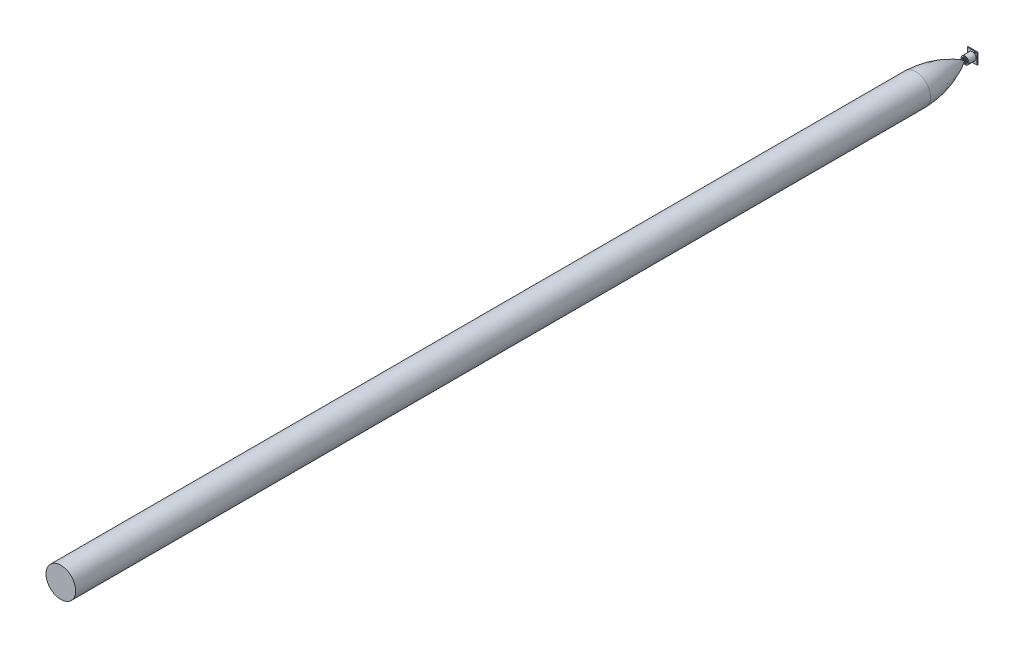
from build123d import *

# Parameters (mm, degrees)
SKETCH1_W          = 19.9
SKETCH1_H          = 22.1
EXTRUDE1_DEPTH     = 1.5875
SKETCH2_R          = 7.747
EXTRUDE2_DEPTH     = 14.7955
SKETCH3_R          = 0.635
EXTRUDE3_DEPTH     = 2.0955
SKETCH5_R          = 1.55
CUT_EXTRUDE1_DEPTH = 2.5875
SKETCH6_R          = 0.5
CUT_EXTRUDE2_DEPTH = 2.5875


with BuildPart() as part:
    # Sketch1 → Extrude1 (new body)
    with BuildSketch(Plane.XY):
        Rectangle(SKETCH1_W, SKETCH1_H)
    extrude(amount=EXTRUDE1_DEPTH)

    # Sketch5 → Cut-Extrude1 (cut, through all)
    with BuildSketch(Plane.XY.offset(1.5875)):
        with Locations((5.19, 8.49)):
            Circle(SKETCH5_R)
        with Locations((-7.41, -8.51)):
            Circle(SKETCH5_R)
    extrude(amount=-CUT_EXTRUDE1_DEPTH, mode=Mode.SUBTRACT)

    # Sketch6 → Cut-Extrude2 (cut, through all)
    with BuildSketch(Plane.XY.offset(1.5875)):
        with Locations((8.75, 5.89)):
            Circle(SKETCH6_R)
        with Locations((8.75, 3.35)):
            Circle(SKETCH6_R)
        with Locations((8.75, 0.81)):
            Circle(SKETCH6_R)
        with Locations((8.75, -1.73)):
            Circle(SKETCH6_R)
        with Locations((8.75, -4.27)):
            Circle(SKETCH6_R)
        with Locations((8.75, -6.81)):
            Circle(SKETCH6_R)
        with Locations((8.75, -9.35)):
            Circle(SKETCH6_R)
    extrude(amount=-CUT_EXTRUDE2_DEPTH, mode=Mode.SUBTRACT)


with BuildPart() as body_2:
    # Sketch2 → Extrude2 (new body)
    with BuildSketch(Plane.XY.offset(1.5875)):
        Circle(SKETCH2_R)
    extrude(amount=EXTRUDE2_DEPTH)

    # Sketch3 → Extrude3 (cut)
    with BuildSketch(Plane.XY.offset(16.383)):
        with BuildLine():
            Line((3.570260811, 2.647878914), (4.675743477, 3.286129629))
            ThreePointArc((4.675743477, 3.286129629), (0, 5.715), (-4.675743477, 3.286129629))
            Line((-4.675743477, 3.286129629), (-3.570260811, 2.647878914))
            ThreePointArc((-3.570260811, 2.647878914), (0, 4.445), (3.570260811, 2.647878914))
        make_face()
        with BuildLine():
            Line((-4.078260811, 1.767997104), (-5.183743477, 2.406247818))
            ThreePointArc((-5.183743477, 2.406247818), (-4.949335183, -2.8575), (-0.508, -5.692377447))
            Line((-0.508, -5.692377447), (-0.508, -4.415876017))
            ThreePointArc((-0.508, -4.415876017), (-3.84948292, -2.2225), (-4.078260811, 1.767997104))
        make_face()
        with BuildLine():
            Line((-0.508, 1.836017701), (-0.508, 3.134096521))
            ThreePointArc((-0.508, 3.134096521), (-2.749630657, 1.5875), (-2.968207205, -1.127107355))
            Line((-2.968207205, -1.127107355), (-1.844037971, -0.478067946))
            ThreePointArc((-1.844037971, -0.478067946), (-1.649778394, 0.9525), (-0.508, 1.836017701))
        make_face()
        with BuildLine():
            Line((-1.336037971, -1.357949756), (-2.460207205, -2.006989165))
            ThreePointArc((-2.460207205, -2.006989165), (0, -3.175), (2.460207205, -2.006989165))
            Line((2.460207205, -2.006989165), (1.336037971, -1.357949756))
            ThreePointArc((1.336037971, -1.357949756), (0, -1.905), (-1.336037971, -1.357949756))
        make_face()
        Circle(SKETCH3_R)
        with BuildLine():
            Line((1.844037971, -0.478067946), (2.968207205, -1.127107355))
            ThreePointArc((2.968207205, -1.127107355), (2.749630657, 1.5875), (0.508, 3.134096521))
            Line((0.508, 3.134096521), (0.508, 1.836017701))
            ThreePointArc((0.508, 1.836017701), (1.649778394, 0.9525), (1.844037971, -0.478067946))
        make_face()
        with BuildLine():
            ThreePointArc((0.508, -4.415876017), (3.84948292, -2.2225), (4.078260811, 1.767997104))
            Line((4.078260811, 1.767997104), (5.183743477, 2.406247818))
            ThreePointArc((5.183743477, 2.406247818), (4.949335183, -2.8575), (0.508, -5.692377447))
            Line((0.508, -5.692377447), (0.508, -4.415876017))
        make_face()
    extrude(amount=-EXTRUDE3_DEPTH, mode=Mode.SUBTRACT)


with BuildPart() as body_3:
    # Sketch7 → Revolve2 (revolve)
    with BuildSketch(Plane(origin=(0, 0, 0), x_dir=(0, 0, -1), z_dir=(1, 0, 0))):
        with BuildLine():
            Line((-115.950137273, 30), (-1845.183, 30))
            Line((-1845.183, 30), (-1845.183, 0))
            Line((-1845.183, 0), (-16.383, 0))
            add(Edge.make_bspline(
                [(-16.383, 0), (-62.194954023, 28.135797835), (-115.950137273, 30)],
                knots=[0, 0, 0, 1, 1, 1], degree=2))
        make_face()
    revolve(axis=Axis((0, 0, 16.383), (0, 0, 1)))


solid = Compound([part.part, body_2.part, body_3.part])
